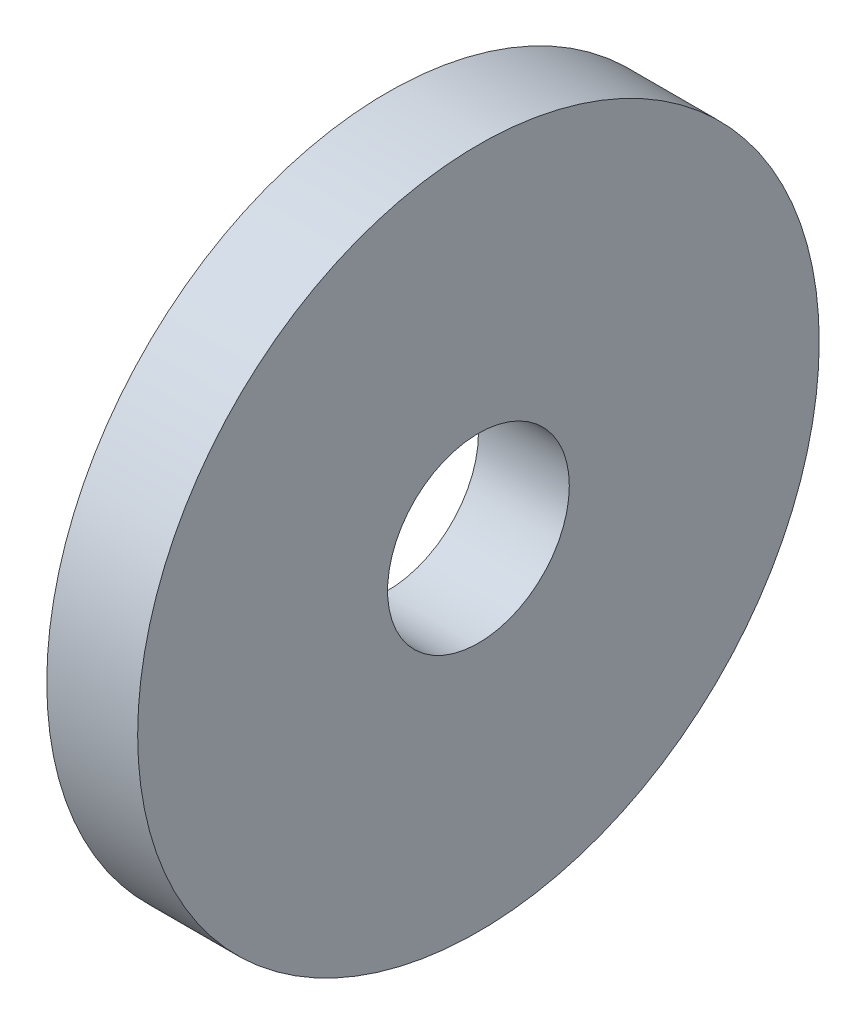
from build123d import *

# Parameters (mm, degrees)
SKETCH_1_R      = 7.5
SKETCH_1_R_2    = 2
EXTRUDE_1_DEPTH = 2


with BuildPart() as part:
    # 草图1 → 凸台-拉伸1 (new body)
    with BuildSketch(Plane(origin=(0, 0, 0), x_dir=(0, 0, -1), z_dir=(1, 0, 0))):
        Circle(SKETCH_1_R)
        Circle(SKETCH_1_R_2, mode=Mode.SUBTRACT)
    extrude(amount=EXTRUDE_1_DEPTH)


solid = part.part
